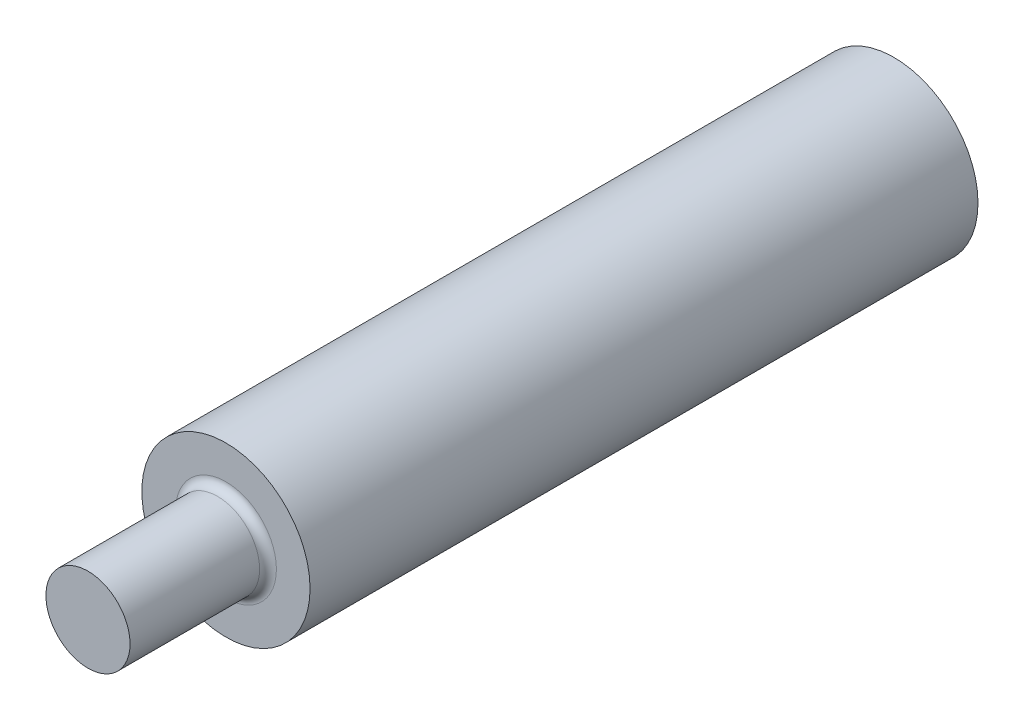
from build123d import *

# Parameters (mm, degrees)
SKETCH1_R           = 25
BOSS_EXTRUDE1_DEPTH = 15
SKETCH2_R           = 50
BOSS_EXTRUDE2_DEPTH = 397
SKETCH3_R           = 25
BOSS_EXTRUDE3_DEPTH = 82
FILLET1_R           = 5


with BuildPart() as part:
    # Sketch1 → Boss-Extrude1 (new body)
    with BuildSketch(Plane.XY):
        Circle(SKETCH1_R)
    extrude(amount=BOSS_EXTRUDE1_DEPTH)

    # Sketch2 → Boss-Extrude2 (add)
    with BuildSketch(Plane.XY.offset(15)):
        Circle(SKETCH2_R)
    extrude(amount=BOSS_EXTRUDE2_DEPTH)

    # Sketch3 → Boss-Extrude3 (add)
    with BuildSketch(Plane.XY.offset(412)):
        Circle(SKETCH3_R)
    extrude(amount=BOSS_EXTRUDE3_DEPTH)

    # Fillet1
    fillet1_edges = [part.edges().sort_by_distance(p)[0] for p in [
        (-25, 0, 15),
        (-25, 0, 412),
    ]]
    fillet(fillet1_edges, radius=FILLET1_R)


solid = part.part
